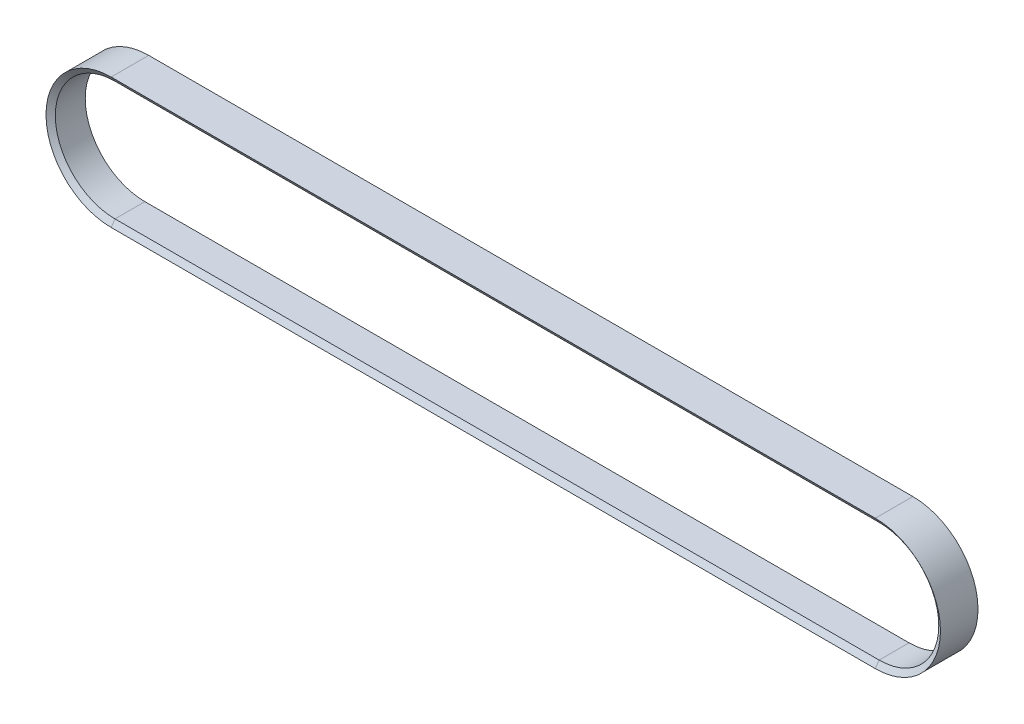
from build123d import *


with BuildPart() as part:
    # Sweep2: sweep along a path in Sketch5
    with BuildLine(Plane.XY) as sweep2_path:
        Line((692, 54), (0, 54))
        ThreePointArc((0, 54), (-54, 0), (0, -54))
        Line((0, -54), (692, -54))
        ThreePointArc((692, -54), (746, 0), (692, 54))
    # Sketch6 → Sweep2 (sweep)
    with BuildSketch(Plane(origin=(0, 0, 0), x_dir=(0, 0, -1), z_dir=(1, 0, 0))):
        Polygon((-13.535, 54), (13.535, 54), (17, 59), (-17, 59), align=None)
    sweep(path=sweep2_path.line)


solid = part.part
